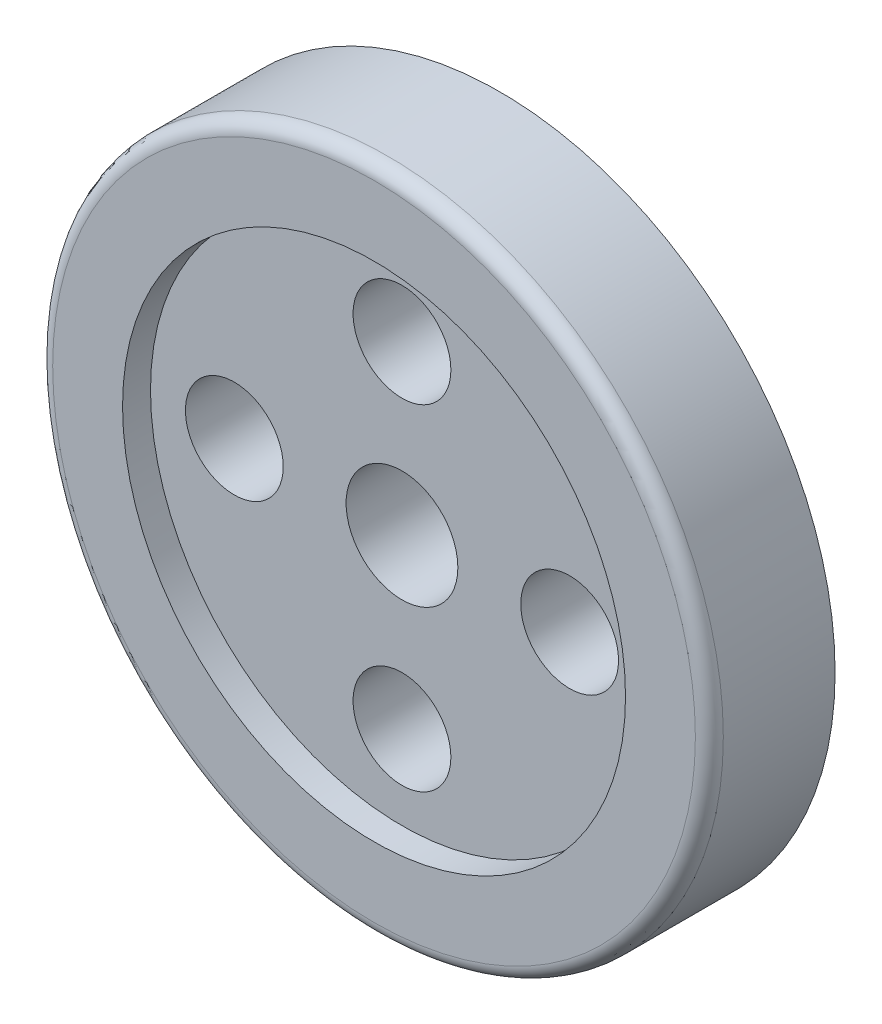
from build123d import *

# Parameters (mm, degrees)
SKETCH1_R           = 24
SKETCH1_R_2         = 18
BOSS_EXTRUDE3_DEPTH = 4.5
BOSS_EXTRUDE4_START = -4.5
SKETCH1_7_R         = 18
SKETCH1_7_R_2       = 3.5
SKETCH1_7_R_3       = 4
BOSS_EXTRUDE4_DEPTH = 7
FILLET1_R           = 1


with BuildPart() as part:
    # Sketch1 → Boss-Extrude3 (new, symmetric)
    with BuildSketch(Plane.XY):
        Circle(SKETCH1_R)
        Circle(SKETCH1_R_2, mode=Mode.SUBTRACT)
    extrude(amount=BOSS_EXTRUDE3_DEPTH, both=True)

    # Sketch1_7 → Boss-Extrude4 (add)
    with BuildSketch(Plane.XY.offset(BOSS_EXTRUDE4_START)):
        Circle(SKETCH1_7_R)
        with Locations((0, -12)):
            Circle(SKETCH1_7_R_2, mode=Mode.SUBTRACT)
        with Locations((-12, 0)):
            Circle(SKETCH1_7_R_2, mode=Mode.SUBTRACT)
        Circle(SKETCH1_7_R_3, mode=Mode.SUBTRACT)
        with Locations((12, 0)):
            Circle(SKETCH1_7_R_2, mode=Mode.SUBTRACT)
        with Locations((0, 12)):
            Circle(SKETCH1_7_R_2, mode=Mode.SUBTRACT)
    extrude(amount=BOSS_EXTRUDE4_DEPTH)

    # Fillet1
    fillet1_edges = [part.edges().sort_by_distance(p)[0] for p in [
        (-24, 0, 4.5),
    ]]
    fillet(fillet1_edges, radius=FILLET1_R)


solid = part.part
